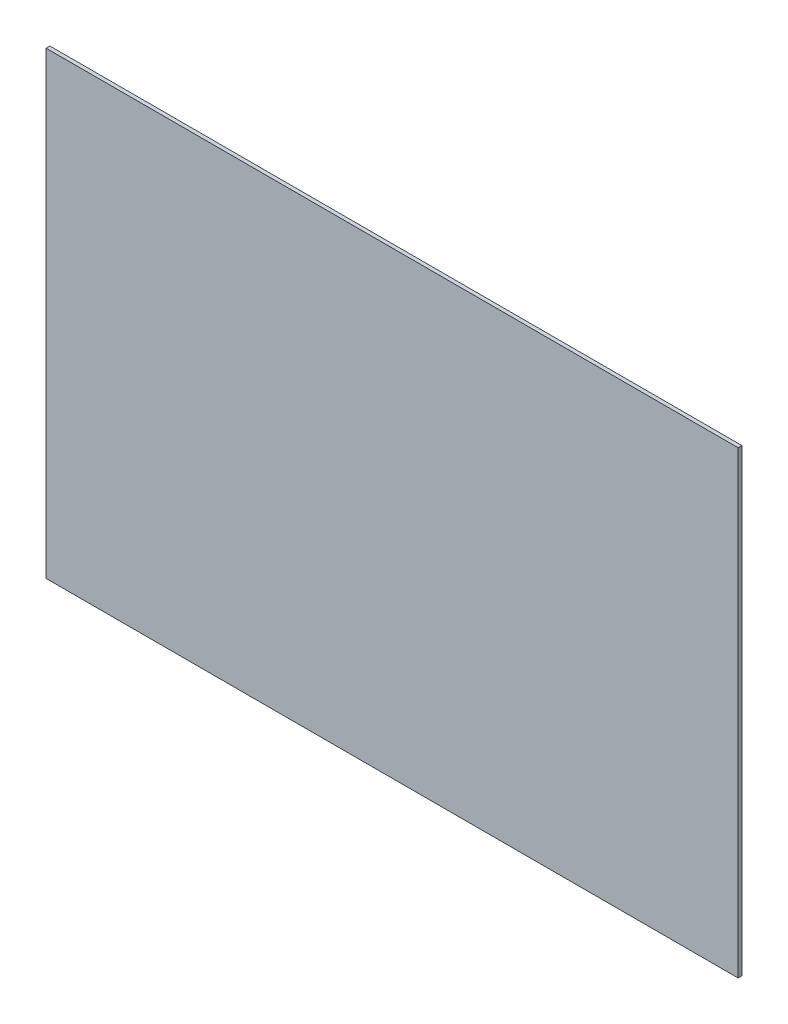
from build123d import *

# Parameters (mm, degrees)
ESQUISSE1_W        = 550
ESQUISSE1_H        = 365
BOSS_EXTRU_1_DEPTH = 3


with BuildPart() as part:
    # Esquisse1 → Boss.-Extru.1 (new body)
    with BuildSketch(Plane.XY):
        with Locations((73.063897764, -41.576677316)):
            Rectangle(ESQUISSE1_W, ESQUISSE1_H)
    extrude(amount=BOSS_EXTRU_1_DEPTH)


solid = part.part
